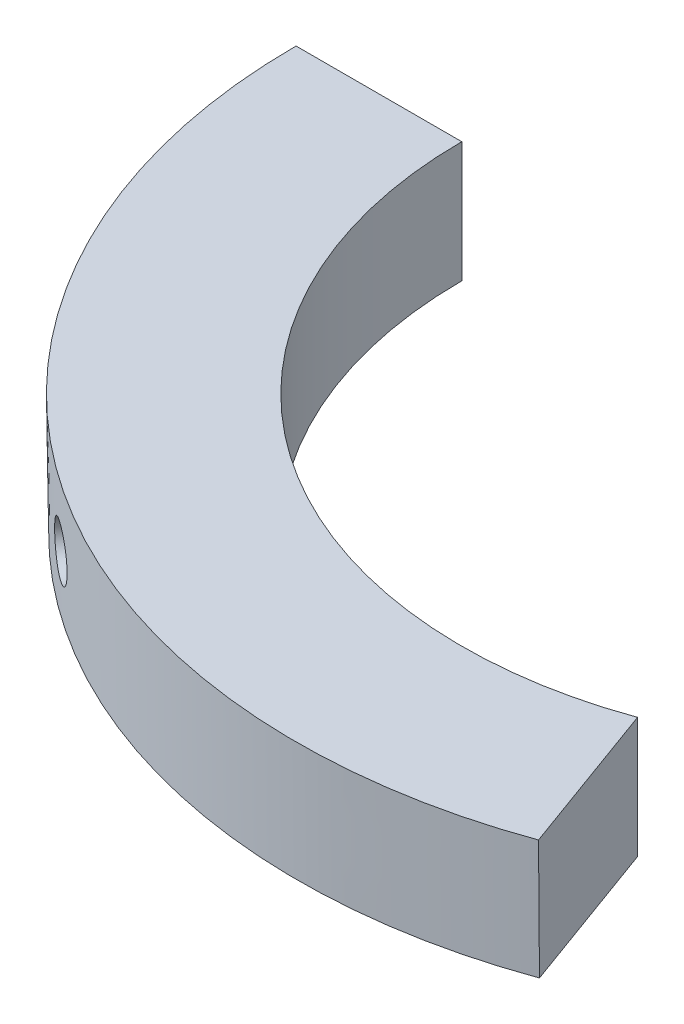
from build123d import *

# Parameters (mm, degrees)
REVOLVE1_ANGLE                                      = 110
CSK_FOR_M3_COUNTERSUNK_FLAT_HEAD_SCREW1_D           = 3.4
CSK_FOR_M3_COUNTERSUNK_FLAT_HEAD_SCREW1_CSINK_D     = 6.3
CSK_FOR_M3_COUNTERSUNK_FLAT_HEAD_SCREW1_CSINK_ANGLE = 90


with BuildPart() as part:
    # Sketch1 → Revolve1 (revolve)
    with BuildSketch(Plane.XY):
        Polygon((-29, 0), (-29, 8), (-40, 8), (-39.896417966, 0.000670605), align=None)
    revolve(axis=Axis((0, 0, 0), (0, 1, 0)), revolution_arc=REVOLVE1_ANGLE)

    # CSK for M3 Countersunk Flat Head Screw1 (through all)
    with Locations(Plane(origin=(-16.693228701, 3.799474552, 23.713627212), x_dir=(-0.817711283, 0, -0.575628576), z_dir=(0.575628576, 0, -0.817711283))):
        with Locations((0, 0)):
            CounterSinkHole(CSK_FOR_M3_COUNTERSUNK_FLAT_HEAD_SCREW1_D / 2, CSK_FOR_M3_COUNTERSUNK_FLAT_HEAD_SCREW1_CSINK_D / 2, counter_sink_angle=CSK_FOR_M3_COUNTERSUNK_FLAT_HEAD_SCREW1_CSINK_ANGLE)


solid = part.part
